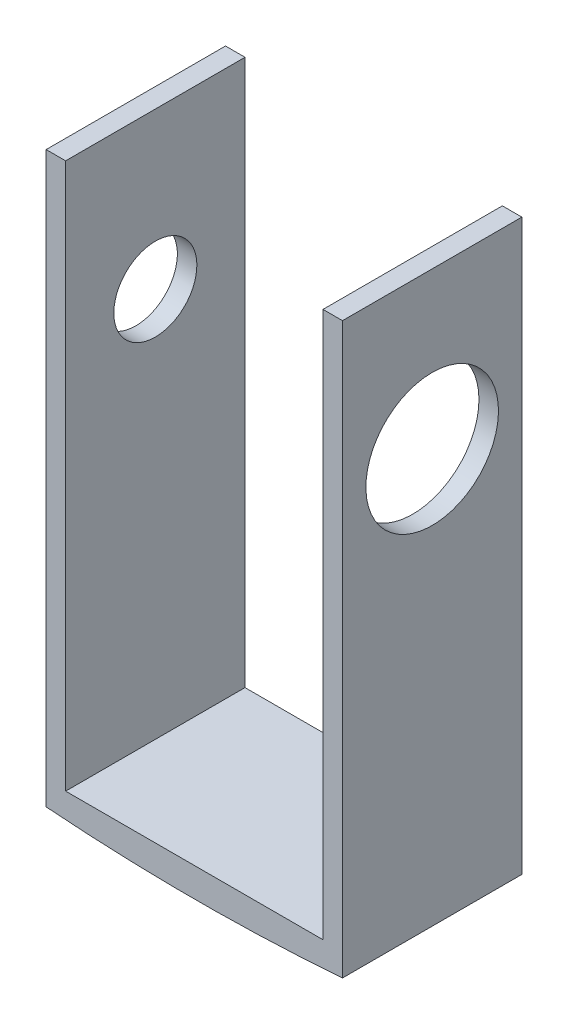
from build123d import *

# Parameters (mm, degrees)
BOSS_EXTRUDE1_DEPTH       = 5.842
BOSS_EXTRUDE2_DEPTH       = 5.842
SKETCH19_R                = 2.159
CUT_EXTRUDE1_DEPTH        = 2.54
F_6_32_TAPPED_HOLE1_D     = 2.7051
F_6_32_TAPPED_HOLE1_DEPTH = 0.635


with BuildPart() as part:
    # Sketch1 → Boss-Extrude1 (new body)
    with BuildSketch(Plane.XY):
        Polygon((-3.034436618, 16.25018662), (-3.034436618, -2.29181338), (6.617563382, -2.29181338), (6.617563382, 16.25018662), (5.982563382, 16.25018662), (5.982563382, -1.52981338), (-2.399436618, -1.52981338), (-2.399436618, 16.25018662), align=None)
    extrude(amount=BOSS_EXTRUDE1_DEPTH)

    # Sketch15 → Boss-Extrude2 (add, through all)
    with BuildSketch(Plane.XY):
        with BuildLine():
            Line((6.617563382, -2.29181338), (-3.034436618, -2.29181338))
            ThreePointArc((-3.034436618, -2.29181338), (1.791563382, -2.477704159), (6.617563382, -2.29181338))
        make_face()
    extrude(amount=BOSS_EXTRUDE2_DEPTH)

    # Sketch19 → Cut-Extrude1 (cut)
    with BuildSketch(Plane(origin=(6.617563382, 0, 0), x_dir=(0, 0, -1), z_dir=(1, 0, 0))):
        with Locations((-2.921, 11.17018662)):
            Circle(SKETCH19_R)
    extrude(amount=-CUT_EXTRUDE1_DEPTH, mode=Mode.SUBTRACT)

    # #6-32 Tapped Hole1
    with Locations(Plane.ZY.offset(3.034436618)):
        with Locations((2.921, 11.17018662)):
            Hole(F_6_32_TAPPED_HOLE1_D / 2, depth=F_6_32_TAPPED_HOLE1_DEPTH)


solid = part.part
